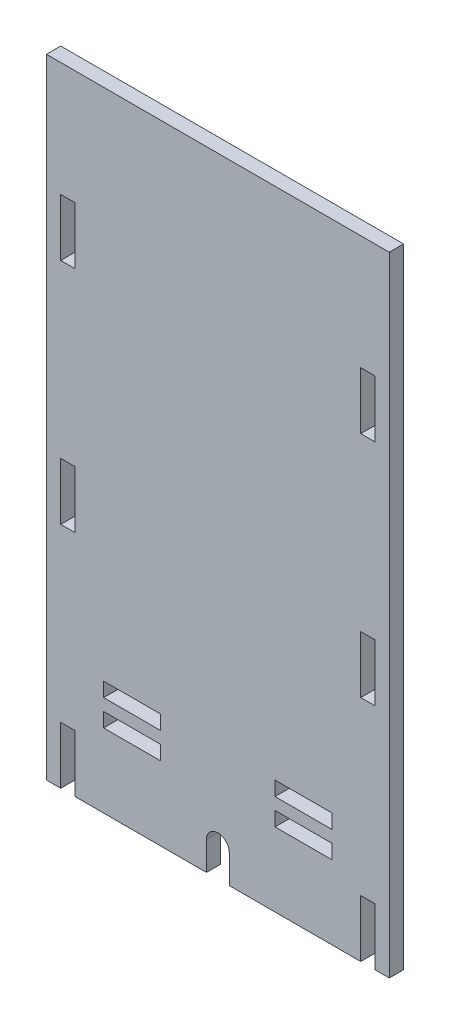
from build123d import *

# Parameters (mm, degrees)
SKETCH1_W            = 76.2
SKETCH1_H            = 139.7
EXTRUDE1_DEPTH       = 3.175
EXTRUDE2_DEPTH       = 4.175
SKETCH3_W            = 12.7
SKETCH3_H            = 3.175
EXTRUDE3_DEPTH       = 4.175
LPATTERN1_COUNT      = 2
LPATTERN1_PITCH      = 38.1
LPATTERN1_COUNT_DIR2 = 2
LPATTERN1_PITCH_DIR2 = 5.842
SKETCH4_W            = 3.175
SKETCH4_H            = 12.7
EXTRUDE4_DEPTH       = 4.175
LPATTERN2_COUNT      = 3
LPATTERN2_PITCH      = 50.8
LPATTERN2_COUNT_DIR2 = 2
LPATTERN2_PITCH_DIR2 = 66.675


with BuildPart() as part:
    # Sketch1 → Extrude1 (new body)
    with BuildSketch(Plane.XY):
        with Locations((38.1, 69.85)):
            Rectangle(SKETCH1_W, SKETCH1_H)
    extrude(amount=EXTRUDE1_DEPTH)

    # Sketch2 → Extrude2 (cut, through all)
    with BuildSketch(Plane.XY.offset(3.175)):
        with BuildLine():
            Line((40.64, 6.35), (40.64, -24.177687884))
            ThreePointArc((40.64, -24.177687884), (38.1, -26.717687884), (35.56, -24.177687884))
            Line((35.56, -24.177687884), (35.56, 6.35))
            ThreePointArc((35.56, 6.35), (38.1, 8.89), (40.64, 6.35))
        make_face()
    extrude(amount=-EXTRUDE2_DEPTH, mode=Mode.SUBTRACT)

    # Sketch3 → Extrude3 (cut, through all)
    with BuildSketch(Plane.XY.offset(3.175)):
        with Locations((19.05, 23.8125)):
            Rectangle(SKETCH3_W, SKETCH3_H)
    extrude3 = extrude(amount=-EXTRUDE3_DEPTH, mode=Mode.SUBTRACT)

    # LPattern1: Extrude3 2 × 2
    with Locations(*[(i * LPATTERN1_PITCH, -j * LPATTERN1_PITCH_DIR2, 0) for i in range(LPATTERN1_COUNT) for j in range(LPATTERN1_COUNT_DIR2) if (i, j) != (0, 0)]):
        add(extrude3, mode=Mode.SUBTRACT)

    # Sketch4 → Extrude4 (cut, through all)
    with BuildSketch(Plane.XY.offset(3.175)):
        with Locations((71.4375, 6.35)):
            Rectangle(SKETCH4_W, SKETCH4_H)
    extrude4 = extrude(amount=-EXTRUDE4_DEPTH, mode=Mode.SUBTRACT)

    # LPattern2: Extrude4 3 × 2
    with Locations(*[(-j * LPATTERN2_PITCH_DIR2, i * LPATTERN2_PITCH, 0) for i in range(LPATTERN2_COUNT) for j in range(LPATTERN2_COUNT_DIR2) if (i, j) != (0, 0)]):
        add(extrude4, mode=Mode.SUBTRACT)


solid = part.part
